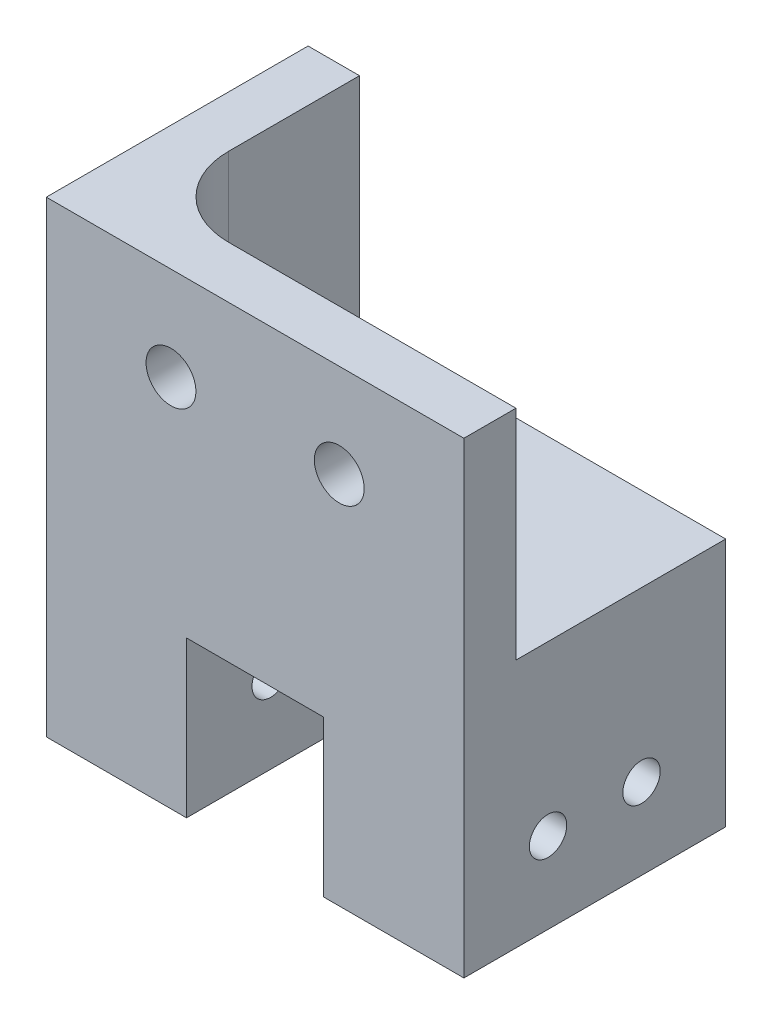
from build123d import *

# Parameters (mm, degrees)
AUFSATZ_LINEAR_AUSTRAGEN1_DEPTH             = 21
AUFSATZ_LINEAR_AUSTRAGEN1_DEPTH_BACK        = 21
SCHNITT_LINEAR_AUSTRAGEN1_DEPTH             = 35
SKIZZE9_R                                   = 4
SCHNITT_LINEAR_AUSTRAGEN2_DEPTH             = 21
SCHNITT_LINEAR_AUSTRAGEN3_REACH             = 35.5
SKIZZE11_R                                  = 3
SCHNITT_LINEAR_AUSTRAGEN3_DIRECTION_2_REACH = 35.5


with BuildPart() as part:
    # Skizze3 → Aufsatz-Linear austragen1 (new body, two sides)
    with BuildSketch(Plane.XY) as aufsatz_linear_austragen1_sk:
        Polygon((0, 205), (33.5, 205), (33.5, 130), (11, 130), (11, 155), (0, 155), (-11, 155), (-11, 130), (-33.5, 130), (-33.5, 205), align=None)
    extrude(amount=AUFSATZ_LINEAR_AUSTRAGEN1_DEPTH)
    extrude(aufsatz_linear_austragen1_sk.sketch, amount=-AUFSATZ_LINEAR_AUSTRAGEN1_DEPTH_BACK)

    # Skizze6 → Schnitt-Linear austragen1 (cut)
    with BuildSketch(Plane(origin=(0, 205, 0), x_dir=(1, 0, 0), z_dir=(0, 1, 0))):
        with BuildLine():
            Line((-25.25, 0), (-25.25, 21))
            Line((-25.25, 21), (33.5, 21))
            Line((33.5, 21), (33.5, -12.65))
            Line((33.5, -12.65), (-12.6, -12.65))
            ThreePointArc((-12.6, -12.65), (-21.544900782, -8.944900782), (-25.25, 0))
        make_face()
    extrude(amount=-SCHNITT_LINEAR_AUSTRAGEN1_DEPTH, mode=Mode.SUBTRACT)

    # Skizze9 → Schnitt-Linear austragen2 (cut)
    with BuildSketch(Plane.XY):
        with Locations((-13.5, 190)):
            Circle(SKIZZE9_R)
        with Locations((13.5, 190)):
            Circle(SKIZZE9_R)
    extrude(amount=SCHNITT_LINEAR_AUSTRAGEN2_DEPTH, mode=Mode.SUBTRACT)

    # Schnitt-Linear austragen3: up to this face of the body (flat: up to its plane)
    schnitt_linear_austragen3_end = Plane(part.part.faces().sort_by_distance((-33.5, 167.5, 0))[0])
    # Skizze11 → Schnitt-Linear austragen3 (cut, up to the picked face)
    with BuildSketch(Plane(origin=(0, 0, 0), x_dir=(0, 0, -1), z_dir=(1, 0, 0)), mode=Mode.PRIVATE) as schnitt_linear_austragen3_sk1:
        with Locations((7.5, 143)):
            Circle(SKIZZE11_R)
    schnitt_linear_austragen3_tool1 = split(extrude(schnitt_linear_austragen3_sk1.sketch, amount=-SCHNITT_LINEAR_AUSTRAGEN3_REACH, mode=Mode.PRIVATE), bisect_by=schnitt_linear_austragen3_end, keep=Keep.BOTH, mode=Mode.PRIVATE)
    add(schnitt_linear_austragen3_tool1.solids().sort_by_distance((0, 143, -7.5))[0], mode=Mode.SUBTRACT)
    # Skizze11 → Schnitt-Linear austragen3 (cut, up to the picked face)
    with BuildSketch(Plane(origin=(0, 0, 0), x_dir=(0, 0, -1), z_dir=(1, 0, 0)), mode=Mode.PRIVATE) as schnitt_linear_austragen3_sk2:
        with Locations((-7.5, 143)):
            Circle(SKIZZE11_R)
    schnitt_linear_austragen3_tool2 = split(extrude(schnitt_linear_austragen3_sk2.sketch, amount=-SCHNITT_LINEAR_AUSTRAGEN3_REACH, mode=Mode.PRIVATE), bisect_by=schnitt_linear_austragen3_end, keep=Keep.BOTH, mode=Mode.PRIVATE)
    add(schnitt_linear_austragen3_tool2.solids().sort_by_distance((0, 143, 7.5))[0], mode=Mode.SUBTRACT)

    # Schnitt-Linear austragen3 direction 2: up to this face of the body (flat: up to its plane)
    schnitt_linear_austragen3_direction_2_end = Plane(part.part.faces().sort_by_distance((33.5, 155.556787933, 2.493145519))[0])
    # Skizze11 → Schnitt-Linear austragen3 direction 2 (cut, up to the picked face)
    with BuildSketch(Plane(origin=(0, 0, 0), x_dir=(0, 0, -1), z_dir=(1, 0, 0)), mode=Mode.PRIVATE) as schnitt_linear_austragen3_direction_2_sk1:
        with Locations((7.5, 143)):
            Circle(SKIZZE11_R)
    schnitt_linear_austragen3_direction_2_tool1 = split(extrude(schnitt_linear_austragen3_direction_2_sk1.sketch, amount=SCHNITT_LINEAR_AUSTRAGEN3_DIRECTION_2_REACH, mode=Mode.PRIVATE), bisect_by=schnitt_linear_austragen3_direction_2_end, keep=Keep.BOTH, mode=Mode.PRIVATE)
    add(schnitt_linear_austragen3_direction_2_tool1.solids().sort_by_distance((0, 143, -7.5))[0], mode=Mode.SUBTRACT)
    # Skizze11 → Schnitt-Linear austragen3 direction 2 (cut, up to the picked face)
    with BuildSketch(Plane(origin=(0, 0, 0), x_dir=(0, 0, -1), z_dir=(1, 0, 0)), mode=Mode.PRIVATE) as schnitt_linear_austragen3_direction_2_sk2:
        with Locations((-7.5, 143)):
            Circle(SKIZZE11_R)
    schnitt_linear_austragen3_direction_2_tool2 = split(extrude(schnitt_linear_austragen3_direction_2_sk2.sketch, amount=SCHNITT_LINEAR_AUSTRAGEN3_DIRECTION_2_REACH, mode=Mode.PRIVATE), bisect_by=schnitt_linear_austragen3_direction_2_end, keep=Keep.BOTH, mode=Mode.PRIVATE)
    add(schnitt_linear_austragen3_direction_2_tool2.solids().sort_by_distance((0, 143, 7.5))[0], mode=Mode.SUBTRACT)


solid = part.part
